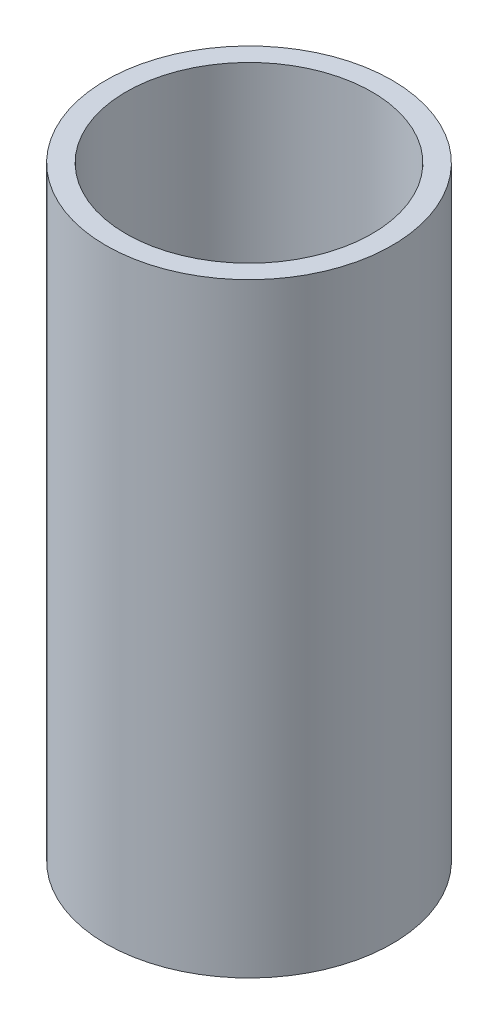
from build123d import *

# Parameters (mm, degrees)
SKETCH1_R           = 7.1
SKETCH1_R_2         = 6.1
BOSS_EXTRUDE1_DEPTH = 30


with BuildPart() as part:
    # Sketch1 → Boss-Extrude1 (new body)
    with BuildSketch(Plane(origin=(0, 0, 0), x_dir=(1, 0, 0), z_dir=(0, 1, 0))):
        Circle(SKETCH1_R)
        Circle(SKETCH1_R_2, mode=Mode.SUBTRACT)
    extrude(amount=BOSS_EXTRUDE1_DEPTH)


solid = part.part
